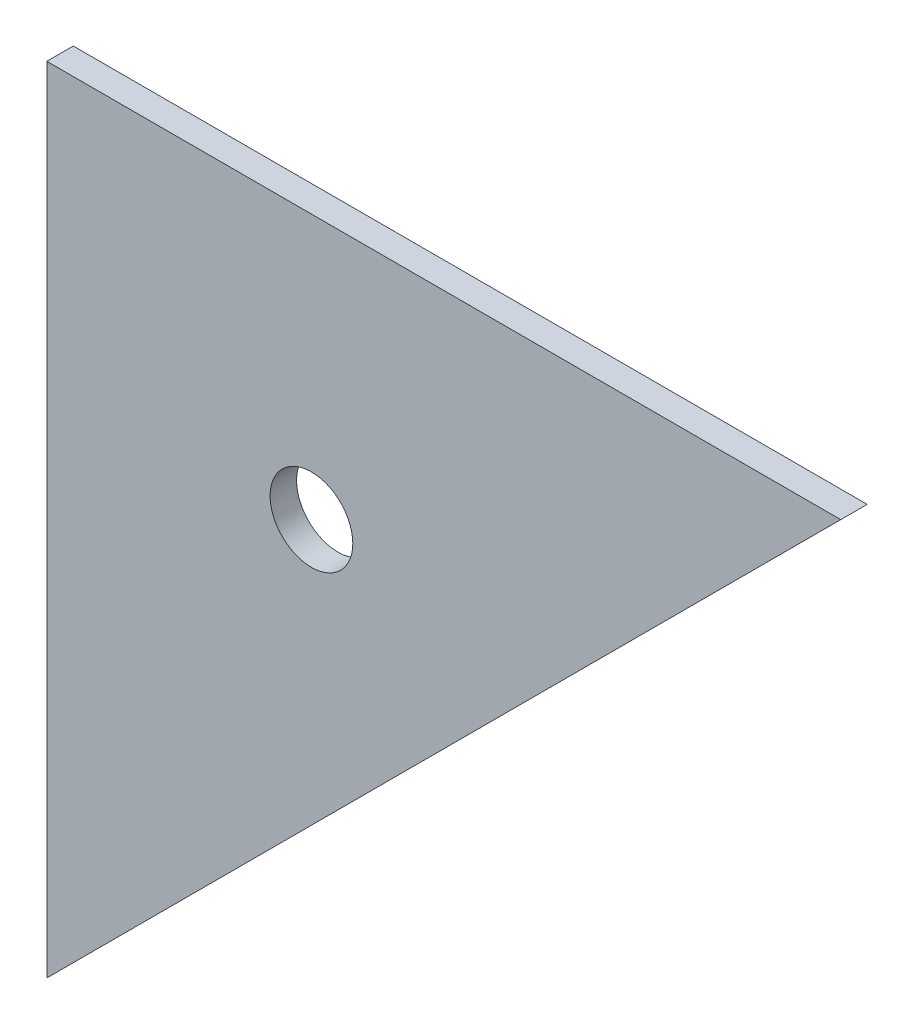
from build123d import *

# Parameters (mm, degrees)
BOSS_EXTRUDE1_DEPTH = 2.54
SKETCH3_R           = 3.96875
CUT_EXTRUDE3_DEPTH  = 101.6


with BuildPart() as part:
    # Sketch1 → Boss-Extrude1 (new body)
    with BuildSketch(Plane.XY):
        Polygon((-5.266755084, 29.049507652), (70.933244916, 29.049507652), (-5.266755084, -47.150492348), align=None)
    extrude(amount=BOSS_EXTRUDE1_DEPTH)

    # Sketch3 → Cut-Extrude3 (cut)
    with BuildSketch(Plane.XY.offset(2.54)):
        with Locations((20.133244916, 3.649507652)):
            Circle(SKETCH3_R)
    extrude(amount=-CUT_EXTRUDE3_DEPTH, mode=Mode.SUBTRACT)


solid = part.part
